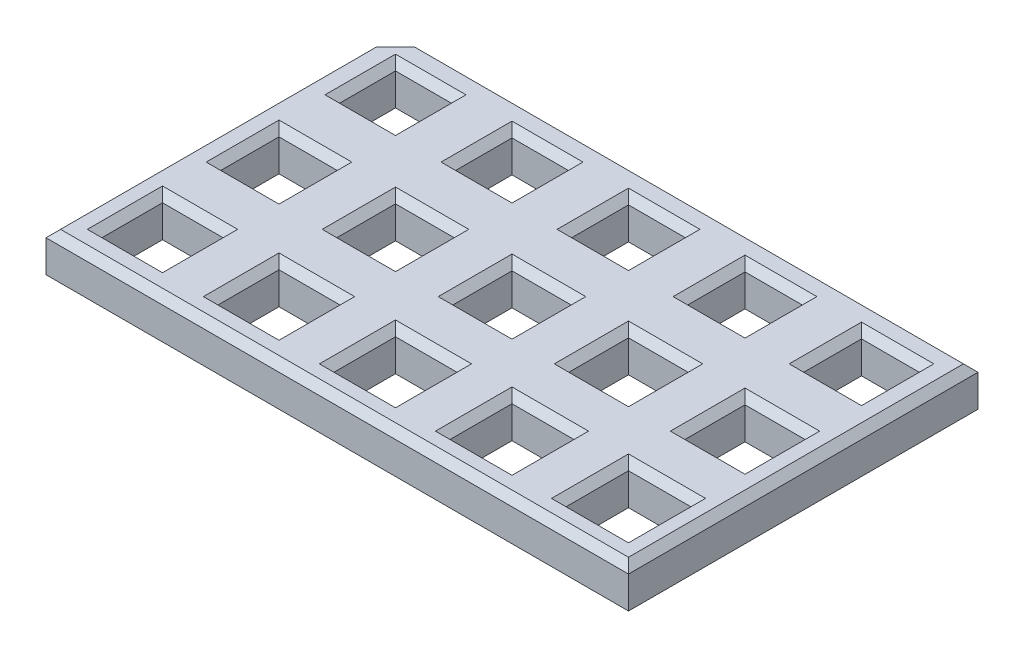
from build123d import *

# Parameters (mm, degrees)
SKETCH1_W           = 31.75
SKETCH1_H           = 19.05
SKETCH1_W_2         = 3.175
SKETCH1_H_2         = 3.175
SKETCH1_W_3         = 3.2004
SKETCH1_H_3         = 3.2004
SKETCH1_W_4         = 3.2258
SKETCH1_H_4         = 3.2258
SKETCH1_W_5         = 3.2512
SKETCH1_H_5         = 3.2512
SKETCH1_W_6         = 3.2766
SKETCH1_H_6         = 3.2766
SKETCH1_W_7         = 3.048
SKETCH1_H_7         = 3.048
SKETCH1_W_8         = 3.0734
SKETCH1_H_8         = 3.0734
SKETCH1_W_9         = 3.0988
SKETCH1_H_9         = 3.0988
SKETCH1_W_10        = 3.1242
SKETCH1_H_10        = 3.1242
SKETCH1_W_11        = 3.1496
SKETCH1_H_11        = 3.1496
SKETCH1_W_12        = 3.302
SKETCH1_H_12        = 3.302
SKETCH1_W_13        = 3.3274
SKETCH1_H_13        = 3.3274
SKETCH1_W_14        = 3.3528
SKETCH1_H_14        = 3.3528
SKETCH1_W_15        = 3.3782
SKETCH1_H_15        = 3.3782
SKETCH1_W_16        = 3.4036
SKETCH1_H_16        = 3.4036
BOSS_EXTRUDE1_DEPTH = 2.54
CHAMFER1_SIZE       = 1.27
CHAMFER2_SIZE       = 0.396875


with BuildPart() as part:
    # Sketch1 → Boss-Extrude1 (new body)
    with BuildSketch(Plane(origin=(0, 0, 0), x_dir=(1, 0, 0), z_dir=(0, 1, 0))):
        with Locations((12.7, 0)):
            Rectangle(SKETCH1_W, SKETCH1_H)
        Rectangle(SKETCH1_W_2, SKETCH1_H_2, mode=Mode.SUBTRACT)
        with Locations((6.35, 0)):
            Rectangle(SKETCH1_W_3, SKETCH1_H_3, mode=Mode.SUBTRACT)
        with Locations((12.7, 0)):
            Rectangle(SKETCH1_W_4, SKETCH1_H_4, mode=Mode.SUBTRACT)
        with Locations((19.05, 0)):
            Rectangle(SKETCH1_W_5, SKETCH1_H_5, mode=Mode.SUBTRACT)
        with Locations((25.4, 0)):
            Rectangle(SKETCH1_W_6, SKETCH1_H_6, mode=Mode.SUBTRACT)
        with Locations((0, 6.35)):
            Rectangle(SKETCH1_W_7, SKETCH1_H_7, mode=Mode.SUBTRACT)
        with Locations((6.35, 6.35)):
            Rectangle(SKETCH1_W_8, SKETCH1_H_8, mode=Mode.SUBTRACT)
        with Locations((12.7, 6.35)):
            Rectangle(SKETCH1_W_9, SKETCH1_H_9, mode=Mode.SUBTRACT)
        with Locations((19.05, 6.35)):
            Rectangle(SKETCH1_W_10, SKETCH1_H_10, mode=Mode.SUBTRACT)
        with Locations((25.4, 6.35)):
            Rectangle(SKETCH1_W_11, SKETCH1_H_11, mode=Mode.SUBTRACT)
        with Locations((0, -6.35)):
            Rectangle(SKETCH1_W_12, SKETCH1_H_12, mode=Mode.SUBTRACT)
        with Locations((6.35, -6.35)):
            Rectangle(SKETCH1_W_13, SKETCH1_H_13, mode=Mode.SUBTRACT)
        with Locations((12.7, -6.35)):
            Rectangle(SKETCH1_W_14, SKETCH1_H_14, mode=Mode.SUBTRACT)
        with Locations((19.05, -6.35)):
            Rectangle(SKETCH1_W_15, SKETCH1_H_15, mode=Mode.SUBTRACT)
        with Locations((25.4, -6.35)):
            Rectangle(SKETCH1_W_16, SKETCH1_H_16, mode=Mode.SUBTRACT)
    extrude(amount=BOSS_EXTRUDE1_DEPTH)

    # Chamfer1
    chamfer1_edges = [part.edges().sort_by_distance(p)[0] for p in [
        (-3.175, 1.27, -9.525),
    ]]
    chamfer(chamfer1_edges, length=CHAMFER1_SIZE)

    # Chamfer2
    chamfer2_edges = [part.edges().sort_by_distance(p)[0] for p in [
        (14.2494, 0, -6.35),
        (12.7, 0, -7.8994),
        (11.1506, 0, -6.35),
        (12.7, 0, -4.8006),
        (14.2494, 2.54, -6.35),
        (12.7, 2.54, -7.8994),
        (11.1506, 2.54, -6.35),
        (12.7, 2.54, -4.8006),
        (20.6121, 0, -6.35),
        (19.05, 0, -7.9121),
        (17.4879, 0, -6.35),
        (19.05, 0, -4.7879),
        (20.6121, 2.54, -6.35),
        (19.05, 2.54, -7.9121),
        (17.4879, 2.54, -6.35),
        (19.05, 2.54, -4.7879),
        (28.575, 2.54, 0),
        (26.9748, 0, -6.35),
        (25.4, 0, -7.9248),
        (23.8252, 0, -6.35),
        (25.4, 0, -4.7752),
        (26.9748, 2.54, -6.35),
        (25.4, 2.54, -7.9248),
        (23.8252, 2.54, -6.35),
        (25.4, 2.54, -4.7752),
        (1.651, 0, 6.35),
        (0, 0, 4.699),
        (-1.651, 0, 6.35),
        (0, 0, 8.001),
        (1.651, 2.54, 6.35),
        (0, 2.54, 4.699),
        (-1.651, 2.54, 6.35),
        (0, 2.54, 8.001),
        (1.5875, 0, 0),
        (0, 0, -1.5875),
        (8.0137, 0, 6.35),
        (6.35, 0, 4.6863),
        (4.6863, 0, 6.35),
        (6.35, 0, 8.0137),
        (8.0137, 2.54, 6.35),
        (6.35, 2.54, 4.6863),
        (4.6863, 2.54, 6.35),
        (6.35, 2.54, 8.0137),
        (-1.5875, 0, 0),
        (0, 0, 1.5875),
        (1.5875, 2.54, 0),
        (13.335, 2.54, -9.525),
        (14.3764, 0, 6.35),
        (12.7, 0, 4.6736),
        (0, 2.54, -1.5875),
        (11.0236, 0, 6.35),
        (12.7, 0, 8.0264),
        (14.3764, 2.54, 6.35),
        (12.7, 2.54, 4.6736),
        (11.0236, 2.54, 6.35),
        (12.7, 2.54, 8.0264),
        (-1.5875, 2.54, 0),
        (0, 2.54, 1.5875),
        (20.7391, 0, 6.35),
        (19.05, 0, 4.6609),
        (17.3609, 0, 6.35),
        (19.05, 0, 8.0391),
        (20.7391, 2.54, 6.35),
        (19.05, 2.54, 4.6609),
        (17.3609, 2.54, 6.35),
        (19.05, 2.54, 8.0391),
        (27.1018, 0, 6.35),
        (25.4, 0, 4.6482),
        (23.6982, 0, 6.35),
        (25.4, 0, 8.0518),
        (27.1018, 2.54, 6.35),
        (25.4, 2.54, 4.6482),
        (23.6982, 2.54, 6.35),
        (25.4, 2.54, 8.0518),
        (-3.175, 0, 0.635),
        (-3.175, 2.54, 0.635),
        (-2.54, 0, -8.89),
        (-2.54, 2.54, -8.89),
        (7.9502, 0, 0),
        (6.35, 0, -1.6002),
        (4.7498, 0, 0),
        (6.35, 0, 1.6002),
        (7.9502, 2.54, 0),
        (6.35, 2.54, -1.6002),
        (4.7498, 2.54, 0),
        (6.35, 2.54, 1.6002),
        (14.3129, 0, 0),
        (12.7, 0, -1.6129),
        (11.0871, 0, 0),
        (12.7, 0, 1.6129),
        (14.3129, 2.54, 0),
        (12.7, 2.54, -1.6129),
        (11.0871, 2.54, 0),
        (12.7, 2.54, 1.6129),
        (13.335, 0, -9.525),
        (28.575, 0, 0),
        (20.6756, 0, 0),
        (19.05, 0, -1.6256),
        (17.4244, 0, 0),
        (19.05, 0, 1.6256),
        (20.6756, 2.54, 0),
        (19.05, 2.54, -1.6256),
        (17.4244, 2.54, 0),
        (19.05, 2.54, 1.6256),
        (12.7, 0, 9.525),
        (27.0383, 0, 0),
        (25.4, 0, -1.6383),
        (23.7617, 0, 0),
        (25.4, 0, 1.6383),
        (27.0383, 2.54, 0),
        (25.4, 2.54, -1.6383),
        (23.7617, 2.54, 0),
        (25.4, 2.54, 1.6383),
        (1.524, 0, -6.35),
        (0, 0, -7.874),
        (-1.524, 0, -6.35),
        (0, 0, -4.826),
        (1.524, 2.54, -6.35),
        (0, 2.54, -7.874),
        (-1.524, 2.54, -6.35),
        (0, 2.54, -4.826),
        (12.7, 2.54, 9.525),
        (7.8867, 0, -6.35),
        (6.35, 0, -7.8867),
        (4.8133, 0, -6.35),
        (6.35, 0, -4.8133),
        (7.8867, 2.54, -6.35),
        (6.35, 2.54, -7.8867),
        (4.8133, 2.54, -6.35),
        (6.35, 2.54, -4.8133),
    ]]
    chamfer(chamfer2_edges, length=CHAMFER2_SIZE)


solid = part.part
